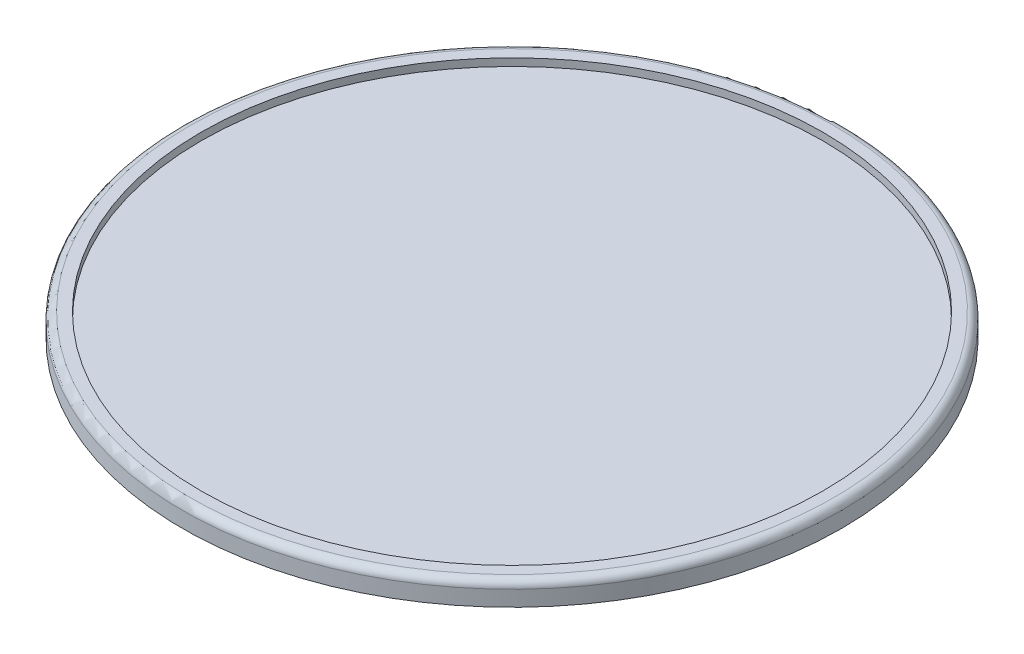
from build123d import *

# Parameters (mm, degrees)
FILLET1_R          = 0.762
SKETCH2_R          = 31.623
CUT_EXTRUDE1_DEPTH = 0.762
CUT_EXTRUDE2_DEPTH = 7.112
CIRPATTERN1_COUNT  = 12


with BuildPart() as part:
    # Sketch1 → Revolve1 (revolve)
    with BuildSketch(Plane.XY):
        Polygon((0, 0), (33.528, 0), (33.528, -2.3495), (20.5232, -2.3495), (20.5232, -9.017), (14.0462, -9.017), (14.0462, -2.3495), (0, -2.3495), align=None)
    revolve(axis=Axis((0, 0, 0), (0, 1, 0)))

    # Fillet1
    fillet1_edges = [part.edges().sort_by_distance(p)[0] for p in [
        (-33.528, 0, 0),
    ]]
    fillet(fillet1_edges, radius=FILLET1_R)

    # Sketch2 → Cut-Extrude1 (cut)
    with BuildSketch(Plane(origin=(0, 0, 0), x_dir=(1, 0, 0), z_dir=(0, 1, 0))):
        Circle(SKETCH2_R)
    extrude(amount=-CUT_EXTRUDE1_DEPTH, mode=Mode.SUBTRACT)

    # Sketch3 → Cut-Extrude2 (cut)
    with BuildSketch(Plane.XZ.offset(9.017)):
        with BuildLine():
            Line((-8.846826654, 16.237553251), (-7.131682909, 13.266837141))
            ThreePointArc((-7.131682909, 13.266837141), (-3.898384221, 14.548967981), (-0.4572, 15.055259446))
            Line((-0.4572, 15.055259446), (-0.4572, 18.485546938))
            ThreePointArc((-0.4572, 18.485546938), (-4.785874727, 17.861127639), (-8.846826654, 16.237553251))
        make_face()
    cut_extrude2 = extrude(amount=-CUT_EXTRUDE2_DEPTH, mode=Mode.SUBTRACT)

    # CirPattern1: Cut-Extrude2 ×12 about axis
    cirpattern1_axis = Axis((0, -2.3495, 0), (0, -1, 0))
    for i in range(1, CIRPATTERN1_COUNT):
        add(cut_extrude2.rotate(cirpattern1_axis, i * 360 / CIRPATTERN1_COUNT), mode=Mode.SUBTRACT)


solid = part.part
